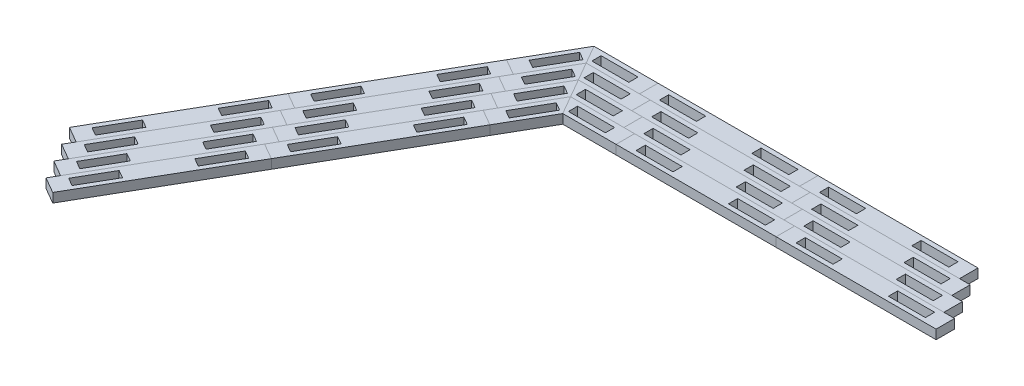
from build123d import *

# Parameters (mm, degrees)
BOSS_EXTRUDE1_DEPTH = 6.35
CUT_EXTRUDE4_DEPTH  = 111.168382488
BOSS_EXTRUDE4_DEPTH = 6.35
CIRPATTERN1_COUNT   = 2
CIRPATTERN1_ANGLE   = 60
SKETCH12_W          = 109.98522628
SKETCH12_H          = 82.55
CUT_EXTRUDE5_DEPTH  = 111.168382488
SKETCH13_W          = 25.4
SKETCH13_H          = 6.35
CUT_EXTRUDE6_DEPTH  = 64.816710194
LPATTERN1_COUNT     = 5
LPATTERN1_PITCH     = 109.985226308
LPATTERN1_2_COUNT   = 2
LPATTERN1_2_PITCH   = 109.985226308
SKETCH14_W          = 25.4
SKETCH14_H          = 6.35
CUT_EXTRUDE7_DEPTH  = 496.991504573
CUT_EXTRUDE8_DEPTH  = 431.162704792
LPATTERN2_COUNT     = 4
LPATTERN2_PITCH     = 14.664696858


with BuildPart() as part:
    # Sketch1 → Boss-Extrude1 (new body)
    with BuildSketch(Plane(origin=(0, 0, 0), x_dir=(1, 0, 0), z_dir=(0, 1, 0))):
        Polygon((-54.99261314, 0), (0, -31.75), (54.99261314, 0), (54.99261314, 63.5), (0, 95.25), (-54.99261314, 63.5), align=None)
    extrude(amount=-BOSS_EXTRUDE1_DEPTH)

    # Sketch10 → Cut-Extrude4 (cut, through all)
    with BuildSketch(Plane(origin=(0, 0, 0), x_dir=(1, 0, 0), z_dir=(0, 1, 0))):
        Polygon((-16.497783942, -22.225), (-7.823522628, -19.900738686), (-24.32130657, -10.375738686), (-27.49630657, -15.875), align=None)
    cut_extrude4 = extrude(amount=-CUT_EXTRUDE4_DEPTH, mode=Mode.SUBTRACT)

    # Sketch11 → Boss-Extrude4 (add)
    with BuildSketch(Plane(origin=(0, 0, 0), x_dir=(1, 0, 0), z_dir=(0, 1, 0))):
        Polygon((-27.49630657, -15.875), (-30.67130657, -21.374261314), (-47.169090512, -11.849261314), (-38.494829198, -9.525), align=None)
    boss_extrude4 = extrude(amount=-BOSS_EXTRUDE4_DEPTH)

    # CirPattern1: Cut-Extrude4, Boss-Extrude4 ×2 about axis
    cirpattern1_axis = Axis((0, 0, -31.75), (0, 1, 0))
    add([cut_extrude4.rotate(cirpattern1_axis, i * CIRPATTERN1_ANGLE / (CIRPATTERN1_COUNT - 1)) for i in range(1, CIRPATTERN1_COUNT)], mode=Mode.SUBTRACT)
    add([boss_extrude4.rotate(cirpattern1_axis, i * CIRPATTERN1_ANGLE / (CIRPATTERN1_COUNT - 1)) for i in range(1, CIRPATTERN1_COUNT)])

    # Sketch12 → Cut-Extrude5 (cut, through all)
    with BuildSketch(Plane(origin=(0, 0, 0), x_dir=(1, 0, 0), z_dir=(0, 1, 0))):
        with Locations((0, 53.975)):
            Rectangle(SKETCH12_W, SKETCH12_H)
    extrude(amount=-CUT_EXTRUDE5_DEPTH, mode=Mode.SUBTRACT)

    # Sketch13 → Cut-Extrude6 (cut, through all)
    with BuildSketch(Plane(origin=(0, 0, 0), x_dir=(1, 0, 0), z_dir=(0, 1, 0))):
        with Locations((-31.75, 6.35)):
            Rectangle(SKETCH13_W, SKETCH13_H)
        with Locations((31.75, 6.35)):
            Rectangle(SKETCH13_W, SKETCH13_H)
    extrude(amount=-CUT_EXTRUDE6_DEPTH, mode=Mode.SUBTRACT)


with BuildPart() as lpattern1_1:
    # LPattern1: pattern copy
    add(part.part.moved(Location(Vector(1, 0, 0) * (1 * LPATTERN1_PITCH))))


with BuildPart() as lpattern1_2:
    # LPattern1: pattern copy
    add(part.part.moved(Location(Vector(1, 0, 0) * (2 * LPATTERN1_PITCH))))


with BuildPart() as lpattern1_3:
    # LPattern1: pattern copy
    add(part.part.moved(Location(Vector(1, 0, 0) * (3 * LPATTERN1_PITCH))))


with BuildPart() as lpattern1_4:
    # LPattern1: pattern copy
    add(part.part.moved(Location(Vector(1, 0, 0) * (4 * LPATTERN1_PITCH))))


with BuildPart() as lpattern1_2_1:
    # LPattern1 2: pattern copy
    add(part.part.moved(Location(Vector(-1, 0, 0) * (1 * LPATTERN1_2_PITCH))))


with BuildPart() as cut_extrude7_tool:
    # Sketch14 → Cut-Extrude7 (new, through all)
    # profile 1 of 2: a face of its own
    with BuildSketch(Plane(origin=(0, 0, 0), x_dir=(1, 0, 0), z_dir=(0, 1, 0))):
        Polygon((423.44312129, -22.225), (439.940905232, -31.75), (456.438689174, -22.225), (454.11442786, -30.899261314), (470.612211802, -21.374261314), (464.262211802, -10.375738686), (480.759995744, -0.850738686), (478.43573443, -9.525), (494.933518372, 0), (494.933518372, 12.7), (428.942382604, 12.7), (415.619598662, -10.375738686), (432.117382604, -19.900738686), align=None)
        with Locations((471.690905232, 6.35)):
            Rectangle(SKETCH14_W, SKETCH14_H, mode=Mode.SUBTRACT)
    # profile 2 of 2: a face of its own
    with BuildSketch(Plane(origin=(0, 0, 0), x_dir=(1, 0, 0), z_dir=(0, 1, 0))):
        Polygon((-164.977839448, -31.75), (-109.985226308, -31.75), (-95.81170368, -30.899261314), (-79.313919738, -21.374261314), (-98.98670368, 12.7), (-164.977839448, 12.7), align=None)
    extrude(amount=-CUT_EXTRUDE7_DEPTH)


with BuildPart() as lpattern1_4_1:
    add(lpattern1_4.part)

    # Cut-Extrude7: cut by cut_extrude7_tool
    add(cut_extrude7_tool.part, mode=Mode.SUBTRACT)


with BuildPart() as lpattern1_2_1_1:
    add(lpattern1_2_1.part)

    # Cut-Extrude7: cut by cut_extrude7_tool
    add(cut_extrude7_tool.part, mode=Mode.SUBTRACT)


with BuildPart() as cut_extrude8_tool:
    # Sketch15 → Cut-Extrude8 (new, through all)
    with BuildSketch(Plane(origin=(0, 0, 0), x_dir=(1, 0, 0), z_dir=(0, 1, 0))):
        Polygon((-222.372160524, 0), (-222.372160524, -63.5), (552.327839476, -63.5), (552.327839476, 12.7), (164.977839476, 12.7), (164.977839476, 0), align=None)
    extrude(amount=-CUT_EXTRUDE8_DEPTH)


with BuildPart() as part_1:
    add(part.part)

    # Cut-Extrude8: cut by cut_extrude8_tool
    add(cut_extrude8_tool.part, mode=Mode.SUBTRACT)


with BuildPart() as lpattern1_1_1:
    add(lpattern1_1.part)

    # Cut-Extrude8: cut by cut_extrude8_tool
    add(cut_extrude8_tool.part, mode=Mode.SUBTRACT)


with BuildPart() as lpattern1_2_2:
    add(lpattern1_2.part)

    # Cut-Extrude8: cut by cut_extrude8_tool
    add(cut_extrude8_tool.part, mode=Mode.SUBTRACT)


with BuildPart() as lpattern1_3_1:
    add(lpattern1_3.part)

    # Cut-Extrude8: cut by cut_extrude8_tool
    add(cut_extrude8_tool.part, mode=Mode.SUBTRACT)


with BuildPart() as lpattern1_4_2:
    add(lpattern1_4_1.part)

    # Cut-Extrude8: cut by cut_extrude8_tool
    add(cut_extrude8_tool.part, mode=Mode.SUBTRACT)


with BuildPart() as lpattern1_2_1_2:
    add(lpattern1_2_1_1.part)

    # Cut-Extrude8: cut by cut_extrude8_tool
    add(cut_extrude8_tool.part, mode=Mode.SUBTRACT)


with BuildPart() as body_4:
    # Mirror1: mirrored copy
    add(lpattern1_2_1_2.part.mirror(Plane(origin=(-68.740766446, -6.35, 39.687500012), x_dir=(0.500000000000001, 0, 0.8660254037844382), z_dir=(0.8660254037844383, 0, -0.5000000000000009))))


with BuildPart() as body_5:
    # Mirror1 2: mirrored copy
    add(part_1.part.mirror(Plane(origin=(-68.740766446, -6.35, 39.687500012), x_dir=(0.500000000000001, 0, 0.8660254037844382), z_dir=(0.8660254037844383, 0, -0.5000000000000009))))


with BuildPart() as body_6:
    # Mirror1 3: mirrored copy
    add(lpattern1_1_1.part.mirror(Plane(origin=(-68.740766446, -6.35, 39.687500012), x_dir=(0.500000000000001, 0, 0.8660254037844382), z_dir=(0.8660254037844383, 0, -0.5000000000000009))))


with BuildPart() as lpattern2_1:
    # LPattern2: pattern copy
    add(lpattern1_1_1.part.moved(Location(Vector(0.5000000000000009, 0, 0.8660254037844383) * (1 * LPATTERN2_PITCH))))


with BuildPart() as lpattern2_2:
    # LPattern2: pattern copy
    add(lpattern1_1_1.part.moved(Location(Vector(0.5000000000000009, 0, 0.8660254037844383) * (2 * LPATTERN2_PITCH))))


with BuildPart() as lpattern2_3:
    # LPattern2: pattern copy
    add(lpattern1_1_1.part.moved(Location(Vector(0.5000000000000009, 0, 0.8660254037844383) * (3 * LPATTERN2_PITCH))))


with BuildPart() as lpattern2_4:
    # LPattern2: pattern copy
    add(part_1.part.moved(Location(Vector(0.5000000000000009, 0, 0.8660254037844383) * (1 * LPATTERN2_PITCH))))


with BuildPart() as lpattern2_5:
    # LPattern2: pattern copy
    add(part_1.part.moved(Location(Vector(0.5000000000000009, 0, 0.8660254037844383) * (2 * LPATTERN2_PITCH))))


with BuildPart() as lpattern2_6:
    # LPattern2: pattern copy
    add(part_1.part.moved(Location(Vector(0.5000000000000009, 0, 0.8660254037844383) * (3 * LPATTERN2_PITCH))))


with BuildPart() as lpattern2_7:
    # LPattern2: pattern copy
    add(lpattern1_2_1_2.part.moved(Location(Vector(0.5000000000000009, 0, 0.8660254037844383) * (1 * LPATTERN2_PITCH))))


with BuildPart() as lpattern2_8:
    # LPattern2: pattern copy
    add(lpattern1_2_1_2.part.moved(Location(Vector(0.5000000000000009, 0, 0.8660254037844383) * (2 * LPATTERN2_PITCH))))


with BuildPart() as lpattern2_9:
    # LPattern2: pattern copy
    add(lpattern1_2_1_2.part.moved(Location(Vector(0.5000000000000009, 0, 0.8660254037844383) * (3 * LPATTERN2_PITCH))))


with BuildPart() as lpattern2_10:
    # LPattern2: pattern copy
    add(body_4.part.moved(Location(Vector(0.5000000000000009, 0, 0.8660254037844383) * (1 * LPATTERN2_PITCH))))


with BuildPart() as lpattern2_11:
    # LPattern2: pattern copy
    add(body_4.part.moved(Location(Vector(0.5000000000000009, 0, 0.8660254037844383) * (2 * LPATTERN2_PITCH))))


with BuildPart() as lpattern2_12:
    # LPattern2: pattern copy
    add(body_4.part.moved(Location(Vector(0.5000000000000009, 0, 0.8660254037844383) * (3 * LPATTERN2_PITCH))))


with BuildPart() as lpattern2_13:
    # LPattern2: pattern copy
    add(body_5.part.moved(Location(Vector(0.5000000000000009, 0, 0.8660254037844383) * (1 * LPATTERN2_PITCH))))


with BuildPart() as lpattern2_14:
    # LPattern2: pattern copy
    add(body_5.part.moved(Location(Vector(0.5000000000000009, 0, 0.8660254037844383) * (2 * LPATTERN2_PITCH))))


with BuildPart() as lpattern2_15:
    # LPattern2: pattern copy
    add(body_5.part.moved(Location(Vector(0.5000000000000009, 0, 0.8660254037844383) * (3 * LPATTERN2_PITCH))))


with BuildPart() as lpattern2_16:
    # LPattern2: pattern copy
    add(body_6.part.moved(Location(Vector(0.5000000000000009, 0, 0.8660254037844383) * (1 * LPATTERN2_PITCH))))


with BuildPart() as lpattern2_17:
    # LPattern2: pattern copy
    add(body_6.part.moved(Location(Vector(0.5000000000000009, 0, 0.8660254037844383) * (2 * LPATTERN2_PITCH))))


with BuildPart() as lpattern2_18:
    # LPattern2: pattern copy
    add(body_6.part.moved(Location(Vector(0.5000000000000009, 0, 0.8660254037844383) * (3 * LPATTERN2_PITCH))))


solid = Compound([part_1.part, lpattern1_1_1.part, lpattern1_2_1_2.part, body_4.part, body_5.part, body_6.part, lpattern2_1.part, lpattern2_2.part, lpattern2_3.part, lpattern2_4.part, lpattern2_5.part, lpattern2_6.part, lpattern2_7.part, lpattern2_8.part, lpattern2_9.part, lpattern2_10.part, lpattern2_11.part, lpattern2_12.part, lpattern2_13.part, lpattern2_14.part, lpattern2_15.part, lpattern2_16.part, lpattern2_17.part, lpattern2_18.part])
